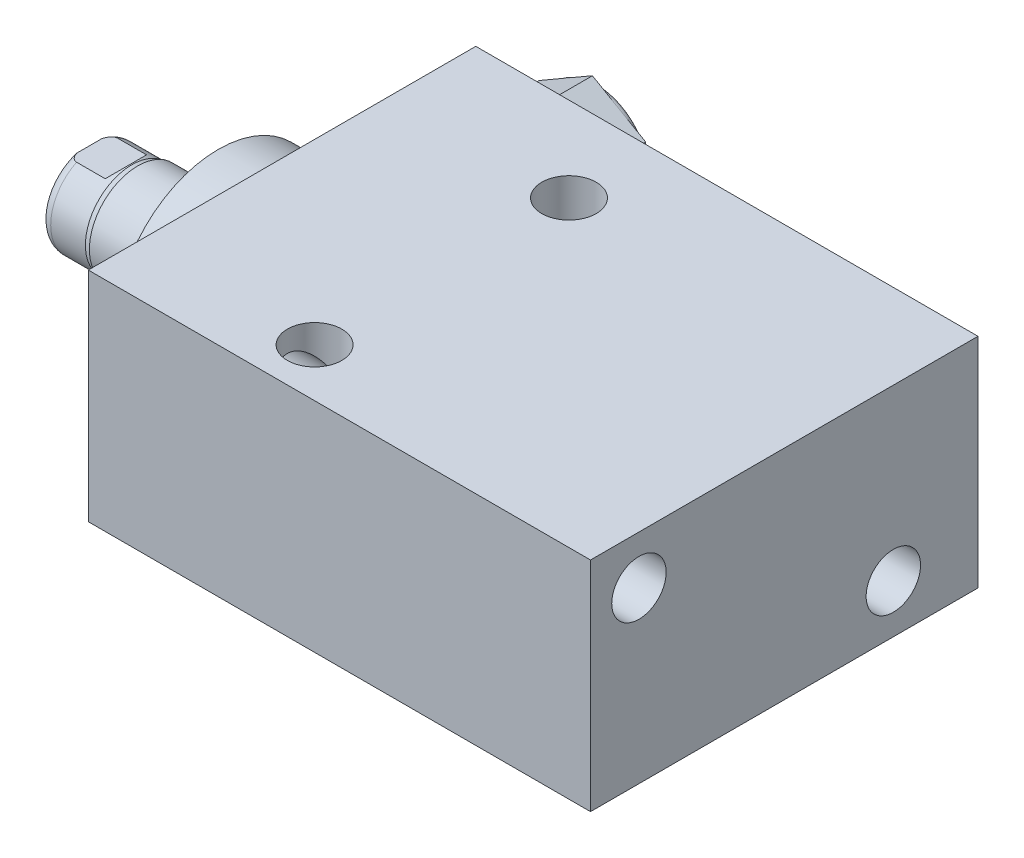
from build123d import *

# Parameters (mm, degrees)
SKETCH1_W          = 50.8
SKETCH1_H          = 28.575
EXTRUDE1_DEPTH     = 65.8368
LPATTERN1_COUNT    = 2
LPATTERN1_PITCH    = 46.99
SKETCH5_R          = 13.5001
EXTRUDE2_DEPTH     = 5.969
SKETCH6_W          = 6.3373
SKETCH6_H          = 16.891
CUT_EXTRUDE4_DEPTH = 30.48
HOLE1_D            = 7.137
HOLE1_DEPTH        = 65.8368
HOLE2_D            = 7.137
HOLE2_DEPTH        = 28.575
EXTRUDE3_DEPTH     = 6.78


with BuildPart() as part:
    # Sketch1 → Extrude1 (new body)
    with BuildSketch(Plane(origin=(0, 0, 0), x_dir=(0, 0, -1), z_dir=(1, 0, 0))):
        with Locations((2.3876, 0)):
            Rectangle(SKETCH1_W, SKETCH1_H)
    extrude(amount=EXTRUDE1_DEPTH)

    # S2D0002 → Cut-Revolve1 (revolve, cut)
    with BuildSketch(Plane(origin=(0, 4.7625, 0), x_dir=(-1, 0, 0), z_dir=(0, 1, 0)), mode=Mode.PRIVATE) as cut_revolve1_sk:
        Polygon((-14.5415, -27.5336), (-18.161, -27.5336), (-18.161, -27.7876), (-9.525, -27.7876), (-9.525, -14.0716), (-13.9446, -14.0716), (-13.9446, -26.9113), (-14.5415, -27.5082), align=None)
    cut_revolve1 = revolve(cut_revolve1_sk.sketch.rotate(Axis((9.525, 4.7625, -19.13842003), (0, 0, 1)), 180), axis=Axis((9.525, 4.7625, -19.13842003), (0, 0, 1)), mode=Mode.SUBTRACT)  # turned: the seam where the file's is

    # LPattern1: Cut-Revolve1 ×2
    with Locations(*[(i * LPATTERN1_PITCH, 0, 0) for i in range(1, LPATTERN1_COUNT)]):
        add(cut_revolve1, mode=Mode.SUBTRACT)

    # Sketch5 → Extrude2 (add)
    with BuildSketch(Plane.ZY):
        Circle(SKETCH5_R)
    extrude(amount=EXTRUDE2_DEPTH)

    # Sketch6 → Revolve1 (revolve)
    with BuildSketch(Plane(origin=(0, 0, 0), x_dir=(0, 0, 1), z_dir=(0, -1, 0)), mode=Mode.PRIVATE) as revolve1_sk:
        with Locations((-3.16865, 14.4145)):
            Rectangle(SKETCH6_W, SKETCH6_H)
    revolve(revolve1_sk.sketch.rotate(Axis((5.754582971, 0, 0), (-1, 0, 0)), 180), axis=Axis((5.754582971, 0, 0), (-1, 0, 0)))  # turned: the seam where the file's is

    # S2D0001 → Cut-Revolve4 (revolve, cut)
    with BuildSketch(Plane(origin=(-18.511260017, 3.2639, 0), x_dir=(0, 1, 0), z_dir=(0, 0, 1)), mode=Mode.PRIVATE) as cut_revolve4_sk:
        Polygon((-0.7493, 2.984923177), (-0.7493, -11.653260017), (-3.2639, -13.16418413), (-3.2639, 4.348739983), (0.0381, 4.348739983), align=None)
    revolve(cut_revolve4_sk.sketch.rotate(Axis((0, 0, 0), (-1, 0, 0)), 90), axis=Axis((0, 0, 0), (-1, 0, 0)), mode=Mode.SUBTRACT)  # turned: the seam where the file's is

    # Sketch8 → Cut-Revolve5 (revolve, cut)
    with BuildSketch(Plane(origin=(0, 0, 0), x_dir=(0, 0, -1), z_dir=(0, 1, 0)), mode=Mode.PRIVATE) as cut_revolve5_sk:
        with BuildLine():
            Line((-6.3373, 16.5354), (-6.096, 17.2974))
            Line((-6.096, 17.2974), (-6.096, 21.844))
            ThreePointArc((-6.096, 21.844), (-5.995678675, 22.387796865), (-5.707922533, 22.86))
            Line((-5.707922533, 22.86), (-6.3373, 22.86))
            Line((-6.3373, 22.86), (-6.3373, 16.5354))
        make_face()
    revolve(cut_revolve5_sk.sketch.rotate(Axis((-12.65936, 0, 0), (-1, 0, 0)), 180), axis=Axis((-12.65936, 0, 0), (-1, 0, 0)), mode=Mode.SUBTRACT)  # turned: the seam where the file's is

    # Sketch12 → Cut-Extrude4 (cut, symmetric)
    with BuildSketch(Plane(origin=(0, 0, 0), x_dir=(0, -1, 0), z_dir=(0, 0, -1))):
        Polygon((5.461, 22.86), (5.461, 18.0848), (6.096, 17.4498), (6.096, 22.86), align=None)
        Polygon((-5.461, 22.86), (-5.461, 18.0848), (-6.096, 17.4498), (-6.096, 22.86), align=None)
    extrude(amount=CUT_EXTRUDE4_DEPTH, both=True, mode=Mode.SUBTRACT)

    # Hole1
    with Locations(Plane.ZY):
        with Locations((-16.6878, -7.9248), (16.6624, 7.9502)):
            Hole(HOLE1_D / 2, depth=HOLE1_DEPTH)

    # Hole2
    with Locations(Plane(origin=(0, 14.2875, 0), x_dir=(-1, 0, 0), z_dir=(0, 1, 0))):
        with Locations((-23.3172, -16.6878), (-23.3172, 16.6624)):
            Hole(HOLE2_D / 2, depth=HOLE2_DEPTH)

    # Sketch18 → Extrude3 (add)
    with BuildSketch(Plane(origin=(0, 0, -27.5336), x_dir=(-1, 0, 0), z_dir=(0, 0, -1))):
        Polygon((-2.54, 8.79529163), (-9.525, 12.828083261), (-16.51, 8.79529163), (-16.51, 0.72970837), (-9.525, -3.303083261), (-2.54, 0.72970837), align=None)
    extrude(amount=EXTRUDE3_DEPTH)

    # Sketch19 → Cut-Revolve6 (revolve, cut)
    with BuildSketch(Plane(origin=(0, 4.7625, 0), x_dir=(-1, 0, 0), z_dir=(0, 1, 0)), mode=Mode.PRIVATE) as cut_revolve6_sk:
        with BuildLine():
            Line((-15.748, -34.3136), (-15.748, -36.7266))
            Line((-15.748, -36.7266), (-18.923, -36.7266))
            Line((-18.923, -36.7266), (-18.923, -33.5516))
            Line((-18.923, -33.5516), (-16.51, -33.5516))
            ThreePointArc((-16.51, -33.5516), (-16.286815367, -34.090415367), (-15.748, -34.3136))
        make_face()
    revolve(cut_revolve6_sk.sketch.rotate(Axis((9.525, 4.7625, -18.51025594), (0, 0, -1)), 180), axis=Axis((9.525, 4.7625, -18.51025594), (0, 0, -1)), mode=Mode.SUBTRACT)  # turned: the seam where the file's is


solid = part.part
